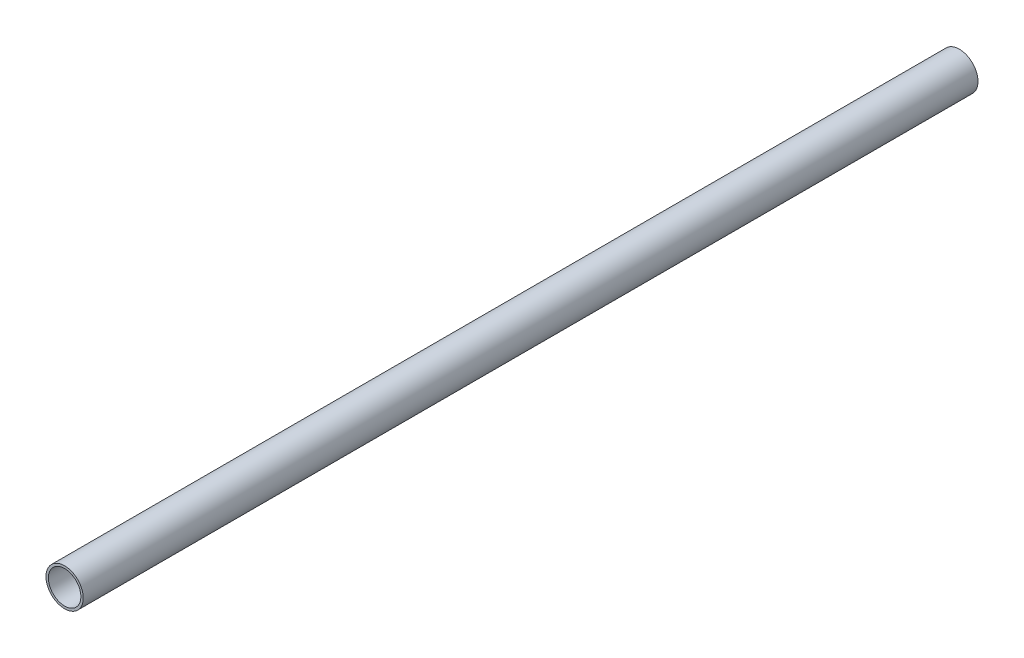
from build123d import *

# Parameters (mm, degrees)
SKETCH2_R           = 6.35
SKETCH2_R_2         = 5.5372
BOSS_EXTRUDE1_DEPTH = 152.4


with BuildPart() as part:
    # Sketch2 → Boss-Extrude1 (new, symmetric)
    with BuildSketch(Plane.XY):
        Circle(SKETCH2_R)
        Circle(SKETCH2_R_2, mode=Mode.SUBTRACT)
    extrude(amount=BOSS_EXTRUDE1_DEPTH, both=True)


solid = part.part
